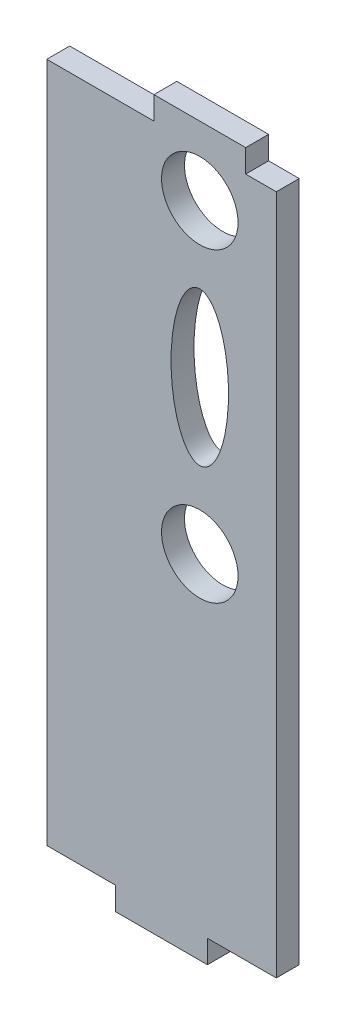
from build123d import *

# Parameters (mm, degrees)
SKETCH_1_R      = 5
SKETCH_1_RX     = 10
SKETCH_1_RY     = 3.757052079
EXTRUDE_1_DEPTH = 3


with BuildPart() as part:
    # 草图1 → 凸台-拉伸1 (new body)
    with BuildSketch(Plane.XY):
        Polygon((555.166453787, 395.688275275), (555.166453787, 306.688275275), (564.166453787, 306.688275275), (564.166453787, 303.688275275), (576.166453787, 303.688275275), (576.166453787, 306.688275275), (585.166453787, 306.688275275), (585.166453787, 395.688275275), (581.166453787, 395.688275275), (581.166453787, 398.688275275), (569.166453787, 398.688275275), (569.166453787, 395.688275275), align=None)
        with Locations((575.166453787, 389.688275275)):
            Circle(SKETCH_1_R, mode=Mode.SUBTRACT)
        with Locations((575.166453787, 349.688275275)):
            Circle(SKETCH_1_R, mode=Mode.SUBTRACT)
        with Locations(Location((575.166453787, 369.688275275), (0, 0, 90))):
            Ellipse(SKETCH_1_RX, SKETCH_1_RY, mode=Mode.SUBTRACT)
    extrude(amount=EXTRUDE_1_DEPTH)


solid = part.part
